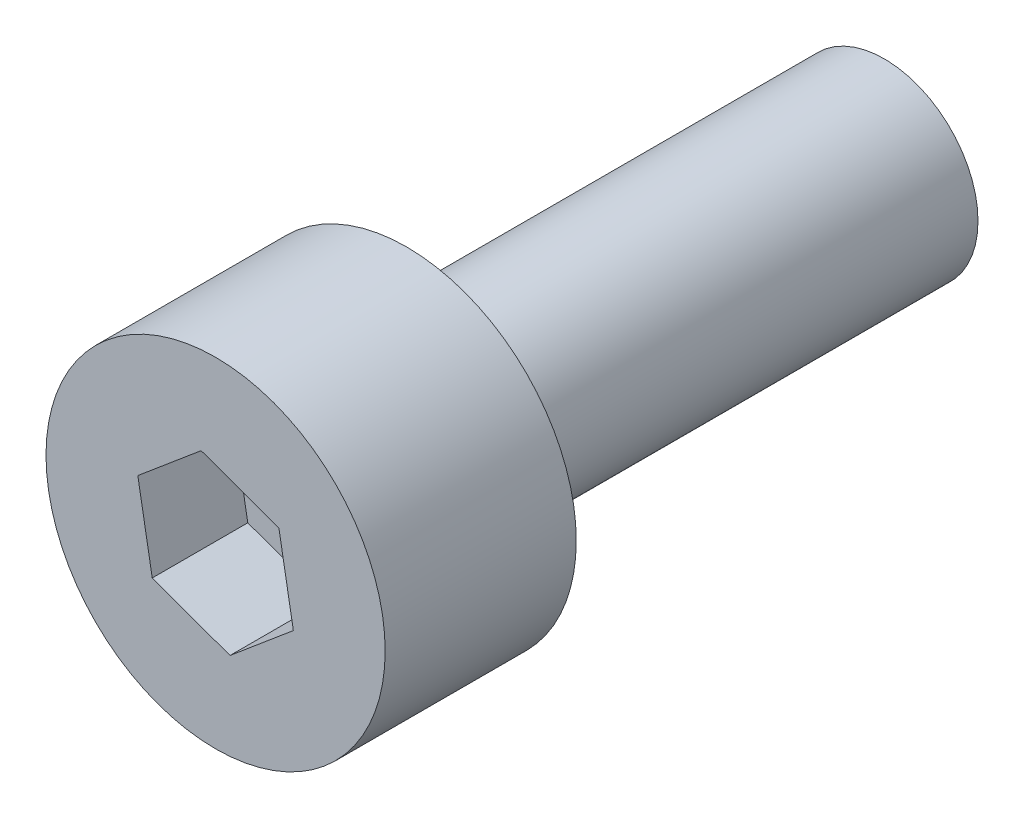
from build123d import *

# Parameters (mm, degrees)
SKETCH1_R           = 1.96
BOSS_EXTRUDE1_DEPTH = 10
SKETCH2_R           = 3.55
BOSS_EXTRUDE2_DEPTH = 4
CUT_EXTRUDE1_DEPTH  = 2


with BuildPart() as part:
    # Sketch1 → Boss-Extrude1 (new body)
    with BuildSketch(Plane.XY):
        Circle(SKETCH1_R)
    extrude(amount=BOSS_EXTRUDE1_DEPTH)

    # Sketch2 → Boss-Extrude2 (add)
    with BuildSketch(Plane.XY.offset(10)):
        Circle(SKETCH2_R)
    extrude(amount=BOSS_EXTRUDE2_DEPTH)

    # Sketch3 → Cut-Extrude1 (cut)
    with BuildSketch(Plane.XY.offset(14)):
        Polygon((1.325823406, 1.114536808), (-0.302305486, 1.705465155), (-1.628128892, 0.590928347), (-1.325823406, -1.114536808), (0.302305486, -1.705465155), (1.628128892, -0.590928347), align=None)
    extrude(amount=-CUT_EXTRUDE1_DEPTH, mode=Mode.SUBTRACT)


solid = part.part
